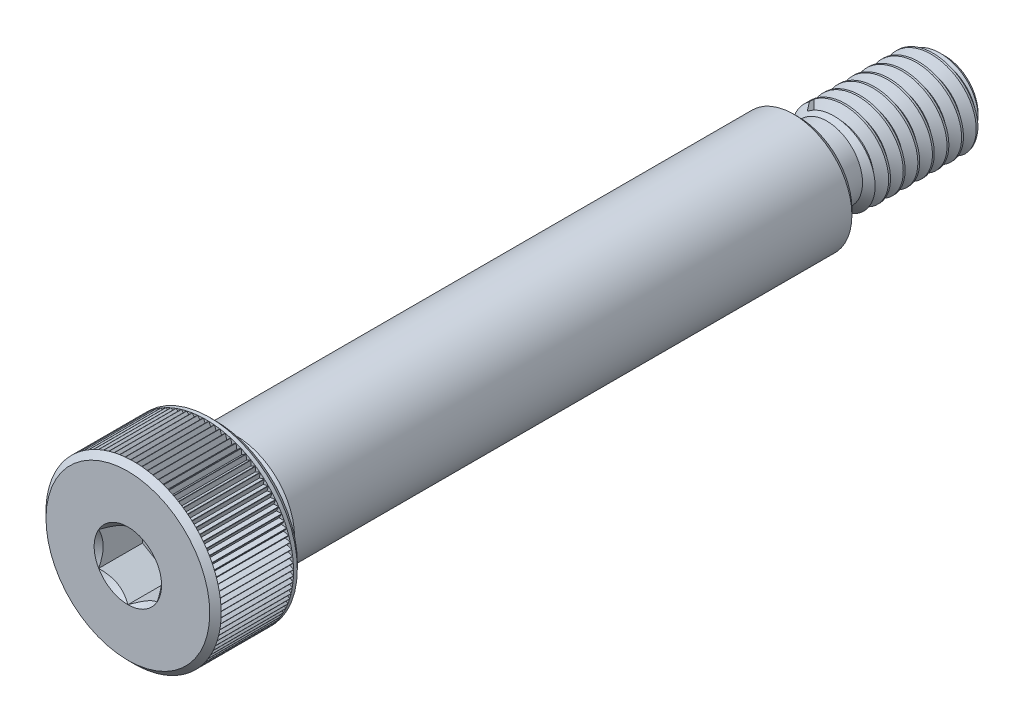
from build123d import *

# Parameters (mm, degrees)
CUT_EXTRUDE1_START     = 14
CUT_EXTRUDE1_DEPTH     = 1.5
CHAMFER1_SIZE          = 0.195
CUT_SWEEP1_PITCH       = 0.5
CUT_SWEEP1_HEIGHT      = 4.05
CUT_SWEEP1_RADIUS      = 1.5
CUT_SWEEP1_START_ANGLE = 90
CUT_EXTRUDE3_START     = 13.805
CUT_EXTRUDE3_DEPTH     = 2.4795
CIRPATTERN1_COUNT      = 99


with BuildPart() as part:
    # Sketch3 → Revolve1 (revolve)
    with BuildSketch(Plane(origin=(0, 0, 0), x_dir=(0, 0, -1), z_dir=(1, 0, 0)), mode=Mode.PRIVATE) as revolve1_sk:
        with BuildLine():
            Line((-14, 0), (-14, 2.805))
            Line((-14, 2.805), (-13.805, 3))
            Line((-13.805, 3), (-11.195, 3))
            Line((-11.195, 3), (-11, 2.805))
            Line((-11, 2.805), (-11, 1.797))
            Line((-11, 1.797), (-10.492, 1.797))
            Line((-10.492, 1.797), (-10.289, 2))
            Line((-10.289, 2), (9, 2))
            Line((9, 2), (9, 1.359375))
            ThreePointArc((9, 1.359375), (9.041188109, 1.259938109), (9.140625, 1.21875))
            Line((9.140625, 1.21875), (9.95, 1.21875))
            Line((9.95, 1.21875), (10.23125, 1.5))
            Line((10.23125, 1.5), (13.625, 1.5))
            Line((13.625, 1.5), (14, 1.125))
            Line((14, 1.125), (14, 0))
            Line((14, 0), (-14, 0))
        make_face()
    revolve(revolve1_sk.sketch.rotate(Axis((0, 0, 14), (0, 0, -1)), 90), axis=Axis((0, 0, 14), (0, 0, -1)))

    # Sketch4 → Cut-Extrude1 (cut)
    with BuildSketch(Plane.XY.offset(CUT_EXTRUDE1_START)):
        Polygon((0, 1.154700538), (-1, 0.577350269), (-1, -0.577350269), (0, -1.154700538), (1, -0.577350269), (1, 0.577350269), align=None)
    extrude(amount=-CUT_EXTRUDE1_DEPTH, mode=Mode.SUBTRACT)

    # Cut-Extrude2 cone 1 section (through the dimple's axis) → Cut-Extrude2 (revolve, cut)
    with BuildSketch(Plane(origin=(0, 0, 14), x_dir=(0, -1, 0), z_dir=(1, 0, 0))):
        Polygon((0, 0), (1.154700538, 0), (0, 1.154700538), align=None)
    revolve(axis=Axis((0, 0, 14), (0, 0, -1)), mode=Mode.SUBTRACT)

    # Chamfer1
    chamfer1_edges = [part.edges().sort_by_distance(p)[0] for p in [
        (-2, 0, -9),
    ]]
    chamfer(chamfer1_edges, length=CHAMFER1_SIZE)

    # Cut-Sweep1: sweep along a helix
    with BuildLine() as cut_sweep1_path:
        add(Helix(CUT_SWEEP1_PITCH, CUT_SWEEP1_HEIGHT, CUT_SWEEP1_RADIUS, center=(0, 0, -14), direction=(0, 0, 1), mode=Mode.PRIVATE).rotate(Axis((0, 0, -14), (0, 0, 1)), CUT_SWEEP1_START_ANGLE))
    # Sketch7 → Cut-Sweep1 (sweep, cut)
    with BuildSketch(Plane(origin=(0, 0, 0), x_dir=(0, 0, -1), z_dir=(1, 0, 0))):
        Polygon((13.984375, 1.527063294), (14.1875, 1.175240474), (14.25, 1.175240474), (14.453125, 1.527063294), align=None)
    sweep(path=cut_sweep1_path.line, is_frenet=True, mode=Mode.SUBTRACT)

    # Sketch8 → Cut-Extrude3 (cut)
    with BuildSketch(Plane.XY.offset(CUT_EXTRUDE3_START)):
        Polygon((-0.090066642, 3), (0.090066642, 3), (0, 2.844), align=None)
    cut_extrude3 = extrude(amount=-CUT_EXTRUDE3_DEPTH, mode=Mode.SUBTRACT)

    # CirPattern1: Cut-Extrude3 ×99 about axis
    cirpattern1_axis = Axis((0, 0, 0), (0, 0, 1))
    for i in range(1, CIRPATTERN1_COUNT):
        add(cut_extrude3.rotate(cirpattern1_axis, i * 360 / CIRPATTERN1_COUNT), mode=Mode.SUBTRACT)


solid = part.part
